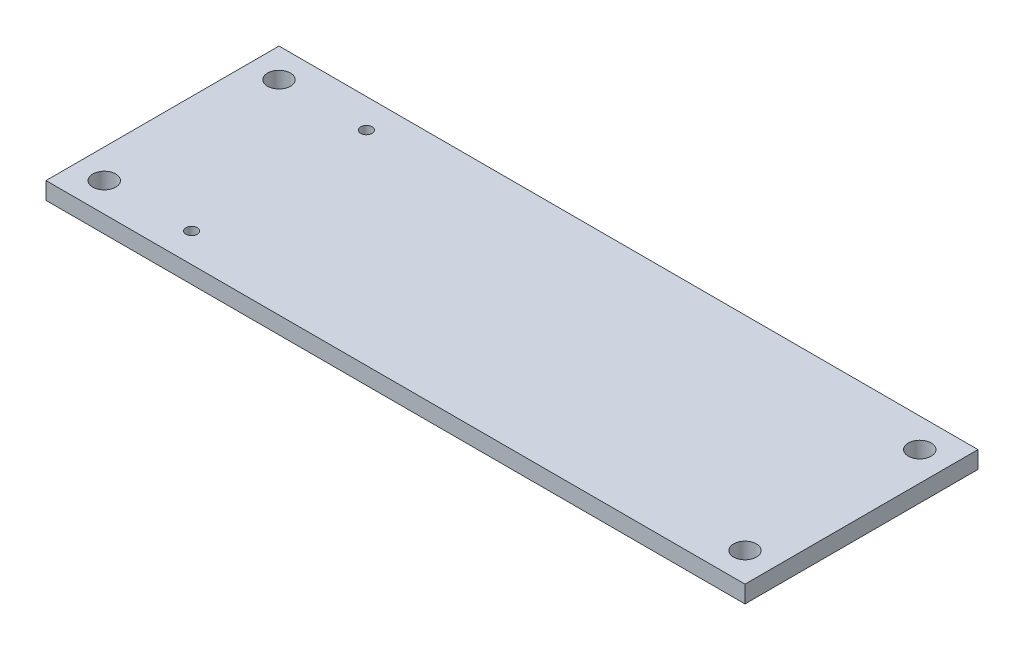
from build123d import *

# Parameters (mm, degrees)
SKETCH1_W           = 60.96
SKETCH1_H           = 20.32
SKETCH1_R           = 1
SKETCH1_R_2         = 0.5
BOSS_EXTRUDE1_DEPTH = 1.5
SKETCH1_3_R         = 0.5
CUT_EXTRUDE3_DEPTH  = 0.03


with BuildPart() as part:
    # Sketch1 → Boss-Extrude1 (new body)
    with BuildSketch(Plane(origin=(0, 0, 0), x_dir=(1, 0, 0), z_dir=(0, 1, 0))):
        with Locations((30.48, 10.16)):
            Rectangle(SKETCH1_W, SKETCH1_H)
        with Locations(Location((2.54, 2.54, 0), (0, 0, 270))):  # turned: the seam where the file's is
            Circle(SKETCH1_R, mode=Mode.SUBTRACT)
        with Locations(Location((58.42, 2.54, 0), (0, 0, 270))):  # turned: the seam where the file's is
            Circle(SKETCH1_R, mode=Mode.SUBTRACT)
        with Locations(Location((58.42, 17.78, 0), (0, 0, 270))):  # turned: the seam where the file's is
            Circle(SKETCH1_R, mode=Mode.SUBTRACT)
        with Locations(Location((2.54, 17.78, 0), (0, 0, 270))):  # turned: the seam where the file's is
            Circle(SKETCH1_R, mode=Mode.SUBTRACT)
        with Locations(Location((10.16, 2.54, 0), (0, 0, 270))):  # turned: the seam where the file's is
            Circle(SKETCH1_R_2, mode=Mode.SUBTRACT)
        with Locations(Location((10.16, 17.78, 0), (0, 0, 270))):  # turned: the seam where the file's is
            Circle(SKETCH1_R_2, mode=Mode.SUBTRACT)
    extrude(amount=BOSS_EXTRUDE1_DEPTH)

    # Sketch1_3 → Cut-Extrude3 (cut)
    with BuildSketch(Plane(origin=(0, 0, 0), x_dir=(1, 0, 0), z_dir=(0, 1, 0))):
        with Locations(Location((55.88, 8.57, 0), (0, 0, 270))):  # turned: the seam where the file's is
            Circle(SKETCH1_3_R)
        with Locations(Location((55.88, 11.11, 0), (0, 0, 90))):  # turned: the seam where the file's is
            Circle(SKETCH1_3_R)
    extrude(amount=CUT_EXTRUDE3_DEPTH, mode=Mode.SUBTRACT)


solid = part.part
